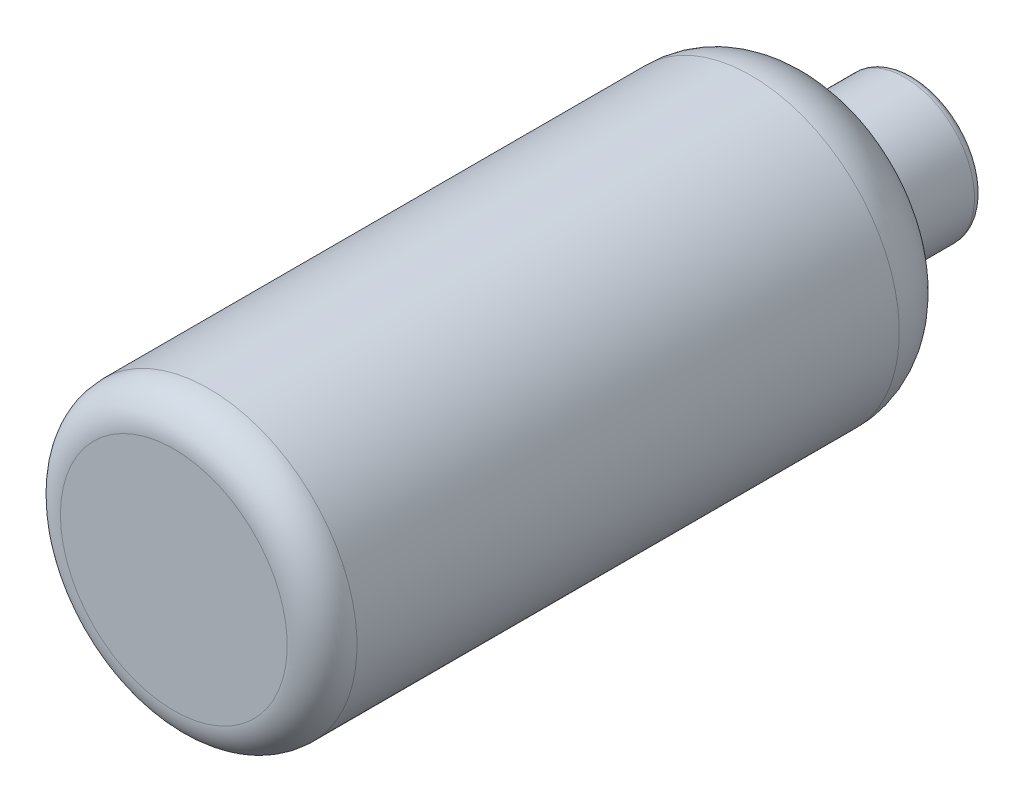
from build123d import *

# Parameters (mm, degrees)
SKETCH2_W = 2.54
SKETCH2_H = 98.700326215


with BuildPart() as part:
    # Sketch2 → Revolve2 (revolve)
    with BuildSketch(Plane(origin=(0, 0, 0), x_dir=(1, 0, 0), z_dir=(0, 1, 0)), mode=Mode.PRIVATE) as revolve2_sk:
        with BuildLine():
            Line((12.7, 120.845751779), (12.7, 133.0325))
            ThreePointArc((12.7, 133.0325), (12.235032015, 134.155032015), (11.1125, 134.62))
            Line((11.1125, 134.62), (10.16, 134.62))
            Line((10.16, 134.62), (10.16, 120.845751779))
            Line((10.16, 120.845751779), (12.7, 120.845751779))
        make_face()
        with BuildLine():
            Line((10.16, 120.845751779), (12.7, 120.845751779))
            ThreePointArc((12.7, 120.845751779), (13.52035698, 118.715897031), (15.5575, 117.686666667))
            ThreePointArc((15.5575, 117.686666667), (23.706072079, 113.56974521), (26.9875, 105.050326215))
            Line((26.9875, 105.050326215), (24.4475, 105.050326215))
            ThreePointArc((24.4475, 105.050326215), (21.822357663, 111.865861411), (15.3035, 115.159398576))
            ThreePointArc((15.3035, 115.159398576), (11.636642565, 117.012013232), (10.16, 120.845751779))
        make_face()
        with Locations((25.7175, 55.700163108)):
            Rectangle(SKETCH2_W, SKETCH2_H)
        with BuildLine():
            Line((24.4475, 6.35), (26.9875, 6.35))
            ThreePointArc((26.9875, 6.35), (25.127628061, 1.859871939), (20.6375, 0))
            Line((20.6375, 0), (0, 0))
            Line((0, 0), (0, 2.54))
            Line((0, 2.54), (20.6375, 2.54))
            ThreePointArc((20.6375, 2.54), (23.331576836, 3.655923164), (24.4475, 6.35))
        make_face()
    revolve(revolve2_sk.sketch.rotate(Axis((0, 0, -132.08), (0, 0, 1)), 180), axis=Axis((0, 0, -132.08), (0, 0, 1)))


solid = part.part
